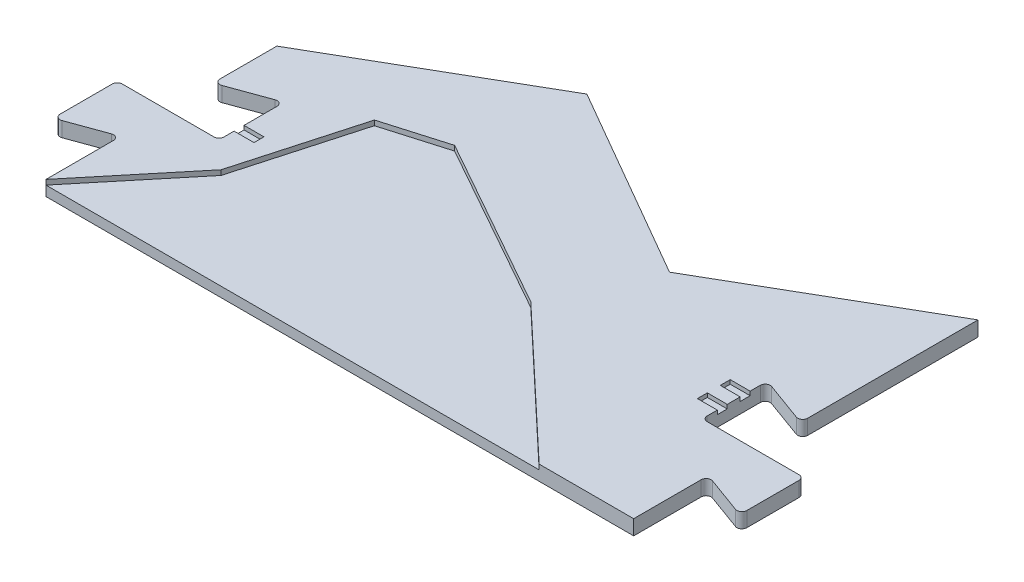
from build123d import *

# Parameters (mm, degrees)
P_IDAT_VYSUNUT_M1_DEPTH  = 3
P_IDAT_VYSUNUT_M2_DEPTH  = 2
ZAOBLIT3_R               = 1
SKICA2_W                 = 4
SKICA2_H                 = 2
ODEBRAT_VYSUNUT_M1_DEPTH = 0.8
SKICA3_W                 = 4
SKICA3_H                 = 2
ODEBRAT_VYSUNUT_M2_DEPTH = 0.8


with BuildPart() as part:
    # Skica1 → P_idat vysunut_m1 (new body)
    with BuildSketch(Plane(origin=(0, 0, 0), x_dir=(1, 0, 0), z_dir=(0, 1, 0))):
        Polygon((-118.143750166, 15), (-118.143750166, 0), (-102.227105248, 19.278496169), (-95.473037065, 43.348863075), (-82.997228437, 47.003202833), (-48.112980408, 27.430537213), (-19, 0), (0, 0), (0, 15), (9.950504516, 11.37831254), (9.950504516, 24.27831254), (-10.5, 24.27831254), (-10.5, 37.37831254), (0, 33.55662508), (0, 69.224902673), (-39.317553332, 46.524902673), (-78.635106664, 69.224902673), (-118.143185584, 46.414902673), (-118.143185584, 33.5570142), (-107.643750166, 37.378496169), (-107.643750166, 24.278496169), (-128.093750166, 24.278496169), (-128.093750166, 11.378496169), align=None)
    extrude(amount=P_IDAT_VYSUNUT_M1_DEPTH)

    # Skica1_3 → P_idat vysunut_m2 (add)
    with BuildSketch(Plane(origin=(0, 0, 0), x_dir=(1, 0, 0), z_dir=(0, 1, 0))):
        Polygon((-102.227105248, 19.278496169), (-118.143750166, 0), (-19, 0), (-48.112980408, 27.430537213), (-82.997228437, 47.003202833), (-95.473037065, 43.348863075), align=None)
    extrude(amount=P_IDAT_VYSUNUT_M2_DEPTH)

    # Zaoblit3
    zaoblit3_edges = [part.edges().sort_by_distance(p)[0] for p in [
        (-107.643750166, 1.5, -24.278496169),
        (0, 1.5, -15),
        (9.950504516, 1.5, -11.37831254),
        (9.950504516, 1.5, -24.27831254),
        (-10.5, 1.5, -24.27831254),
        (-10.5, 1.5, -37.37831254),
        (0, 1.5, -33.55662508),
        (-118.143750166, 1.5, -15),
        (-128.093750166, 1.5, -11.378496169),
        (-128.093750166, 1.5, -24.278496169),
        (-107.643750166, 1.5, -37.378496169),
        (-118.143185584, 1.5, -33.5570142),
    ]]
    fillet(zaoblit3_edges, radius=ZAOBLIT3_R)

    # Skica2 → Odebrat vysunut_m1 (cut)
    with BuildSketch(Plane(origin=(0, 3, 0), x_dir=(1, 0, 0), z_dir=(0, 1, 0))):
        with Locations((-105.643750166, 28.314422166)):
            Rectangle(SKICA2_W, SKICA2_H)
    extrude(amount=-ODEBRAT_VYSUNUT_M1_DEPTH, mode=Mode.SUBTRACT)

    # Skica3 → Odebrat vysunut_m2 (cut)
    with BuildSketch(Plane(origin=(0, 3, 0), x_dir=(1, 0, 0), z_dir=(0, 1, 0))):
        with Locations((-12.5, 32.914238537)):
            Rectangle(SKICA3_W, SKICA3_H)
        with Locations((-12.5, 28.314238537)):
            Rectangle(SKICA3_W, SKICA3_H)
    extrude(amount=-ODEBRAT_VYSUNUT_M2_DEPTH, mode=Mode.SUBTRACT)


solid = part.part
